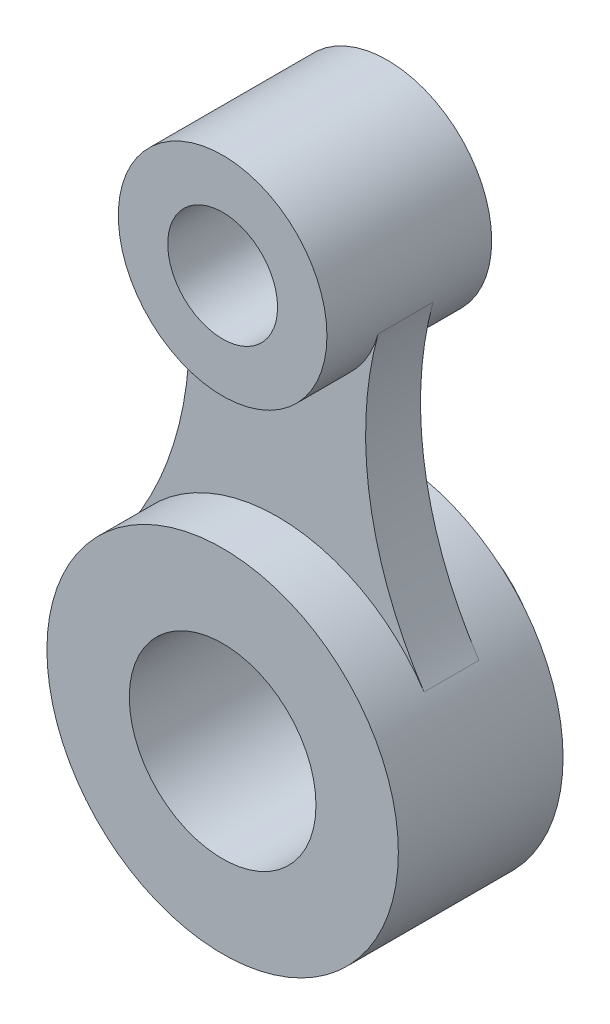
from build123d import *

# Parameters (mm, degrees)
ESQUISSE1_R             = 32
ESQUISSE1_R_2           = 17
BOSS_EXTRU_1_DEPTH      = 15
ESQUISSE1_R_3           = 19
ESQUISSE1_R_4           = 10
BOSS_EXTRU_1_2_DEPTH    = 15
BOSS_EXTRU_2_DEPTH      = 5
ESQUISSE3_R             = 27.5
ESQUISSE3_R_2           = 21.5
ENL_V_MAT_EXTRU_1_DEPTH = 5
ESQUISSE4_R             = 21.5
ESQUISSE4_R_2           = 17
BOSS_EXTRU_3_DEPTH      = 7.5


with BuildPart() as part:
    # Esquisse1 → Boss.-Extru.1 (new body, symmetric)
    with BuildSketch(Plane.XY):
        Circle(ESQUISSE1_R)
        Circle(ESQUISSE1_R_2, mode=Mode.SUBTRACT)
    extrude(amount=BOSS_EXTRU_1_DEPTH, both=True)



with BuildPart() as body_2:
    # Esquisse1 → Boss.-Extru.1 2 (new body, symmetric)
    with BuildSketch(Plane.XY):
        with Locations((0, 75)):
            Circle(ESQUISSE1_R_3)
        with Locations((0, 75)):
            Circle(ESQUISSE1_R_4, mode=Mode.SUBTRACT)
    extrude(amount=BOSS_EXTRU_1_2_DEPTH, both=True)


with BuildPart() as part_1:
    add(part.part)

    add(body_2.part)  # Boss.-Extru.2 merges body 2
    # Esquisse2 → Boss.-Extru.2 (add, symmetric)
    with BuildSketch(Plane.XY):
        with BuildLine():
            ThreePointArc((26.678302647, 17.671111111), (0, 32), (-26.678302647, 17.671111111))
            ThreePointArc((-26.678302647, 17.671111111), (-16.836772686, 42.914041255), (-18.321243986, 69.966907631))
            ThreePointArc((-18.321243986, 69.966907631), (0, 56), (18.321243986, 69.966907631))
            ThreePointArc((18.321243986, 69.966907631), (16.836772686, 42.914041255), (26.678302647, 17.671111111))
        make_face()
    extrude(amount=BOSS_EXTRU_2_DEPTH, both=True)

    # Esquisse3 → Enlèv. mat.-Extru.1 (cut)
    with BuildSketch(Plane(origin=(0, 0, -15), x_dir=(-1, 0, 0), z_dir=(0, 0, -1))):
        Circle(ESQUISSE3_R)
        Circle(ESQUISSE3_R_2, mode=Mode.SUBTRACT)
    extrude(amount=-ENL_V_MAT_EXTRU_1_DEPTH, mode=Mode.SUBTRACT)

    # Esquisse4 → Boss.-Extru.3 (add, symmetric)
    with BuildSketch(Plane(origin=(0, 0, -15), x_dir=(-1, 0, 0), z_dir=(0, 0, -1))):
        Circle(ESQUISSE4_R)
        Circle(ESQUISSE4_R_2, mode=Mode.SUBTRACT)
    extrude(amount=BOSS_EXTRU_3_DEPTH, both=True)


solid = part_1.part
